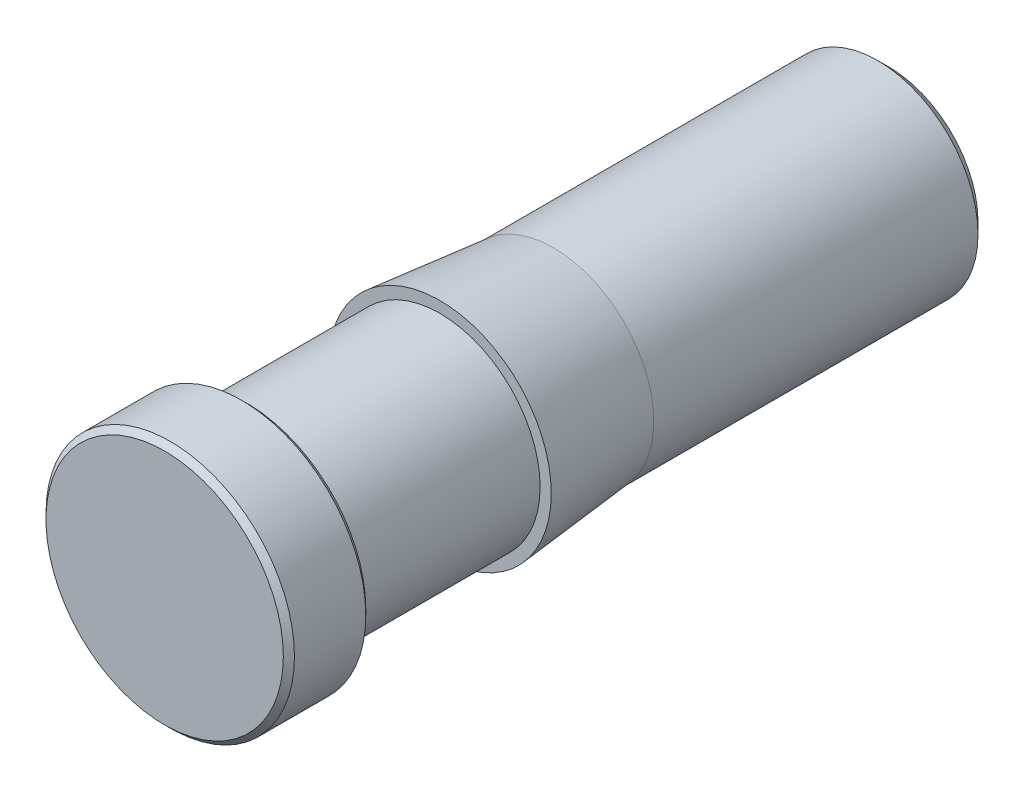
from build123d import *


with BuildPart() as part:
    # Esquisse1 → Révolution1 (revolve)
    with BuildSketch(Plane(origin=(0, 0, 0), x_dir=(1, 0, 0), z_dir=(0, 1, 0))):
        Polygon((0.65, 5.17), (0, 4.794722325), (0, 0), (1.065, 0), (1.115, 0.05), (1.115, 0.69), (1.065, 0.74), (0.9, 0.74), (0.9, 2.47), (1, 2.47), (0.9, 3.49), (0.9, 6.4), (0.8, 6.5), (0.7, 6.5), (0.65, 6.45), align=None)
    revolve(axis=Axis((0, 0, -6.5), (0, 0, 1)))


solid = part.part
